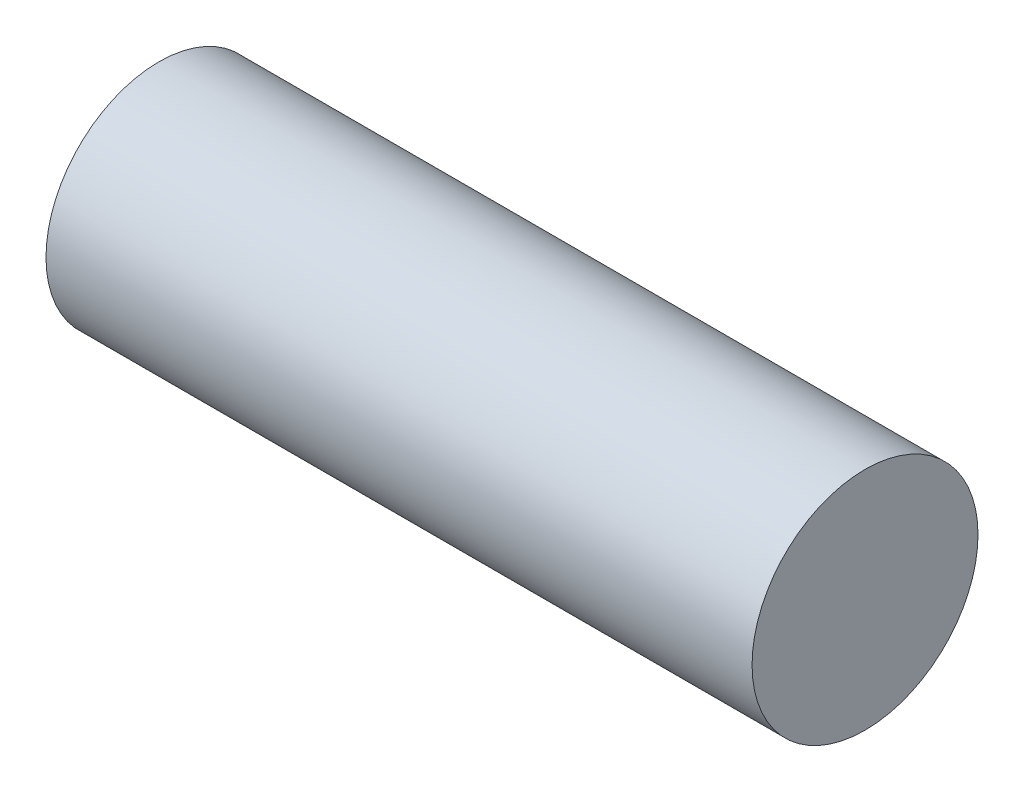
from build123d import *

# Parameters (mm, degrees)
SCHIZZO1_R                   = 4
ESTRUSIONE_ESTRUSIONE1_DEPTH = 25


with BuildPart() as part:
    # Schizzo1 → Estrusione-Estrusione1 (new body)
    with BuildSketch(Plane(origin=(0, 0, 0), x_dir=(0, 0, -1), z_dir=(1, 0, 0))):
        Circle(SCHIZZO1_R)
    extrude(amount=ESTRUSIONE_ESTRUSIONE1_DEPTH)


solid = part.part
